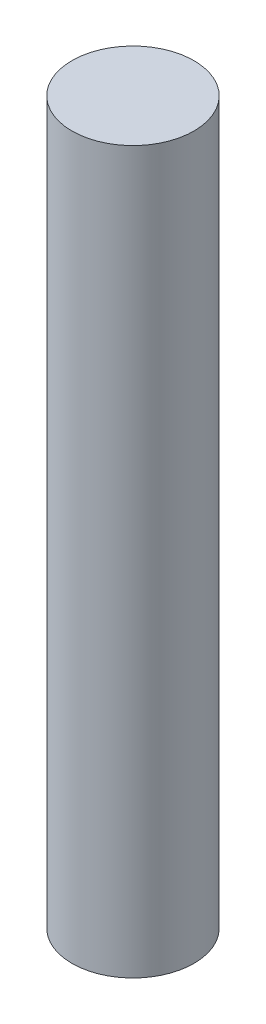
from build123d import *

# Parameters (mm, degrees)
SKETCH1_R           = 1.1
BOSS_EXTRUDE1_DEPTH = 13


with BuildPart() as part:
    # Sketch1 → Boss-Extrude1 (new body)
    with BuildSketch(Plane(origin=(0, 0, 0), x_dir=(1, 0, 0), z_dir=(0, 1, 0))):
        Circle(SKETCH1_R)
    extrude(amount=BOSS_EXTRUDE1_DEPTH)


solid = part.part
